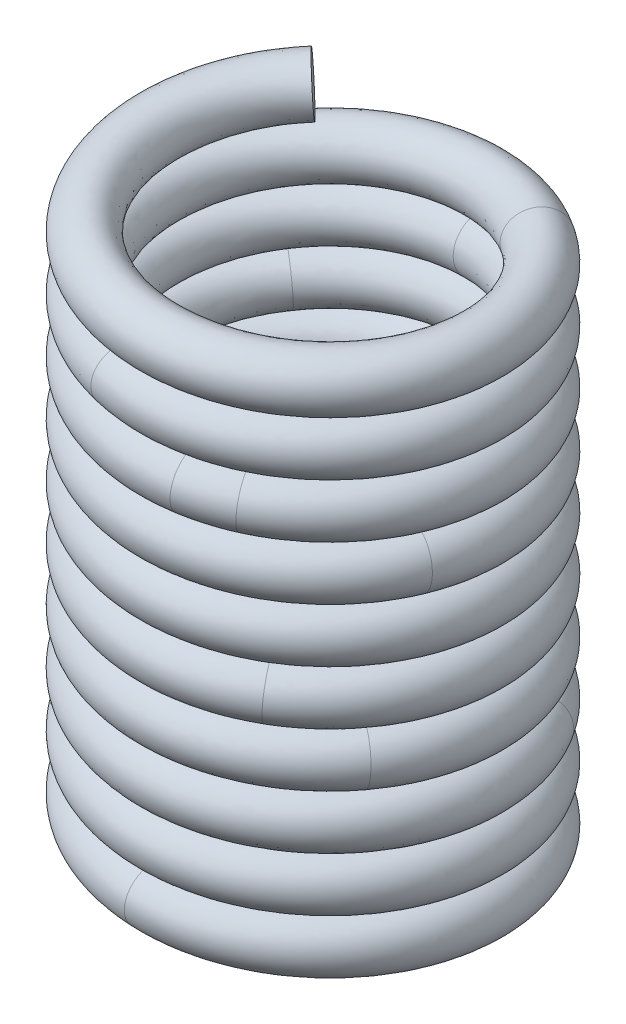
from build123d import *

# Parameters (mm, degrees)
SWEEP_1_PITCH       = 20
SWEEP_1_HEIGHT      = 200
SWEEP_1_RADIUS      = 60
SWEEP_1_START_ANGLE = -135
SKETCH_3_R          = 10


with BuildPart() as part:
    # 스윕1: sweep along a helix
    with BuildLine() as sweep_1_path:
        add(Helix(SWEEP_1_PITCH, SWEEP_1_HEIGHT, SWEEP_1_RADIUS, center=(0, 0, 0), direction=(0, 1, 0), lefthand=True, mode=Mode.PRIVATE).rotate(Axis((0, 0, 0), (0, 1, 0)), SWEEP_1_START_ANGLE))
    # 스케치3 → 스윕1 (sweep)
    with BuildSketch(Plane(origin=(-42.426406871, 0, -42.426406871), x_dir=(-0.708098361, 0.052828672, -0.704134818), z_dir=(0.706113809, 0.052977149, -0.706113809))):
        Circle(SKETCH_3_R)
    sweep(path=sweep_1_path.line, is_frenet=True)


solid = part.part
